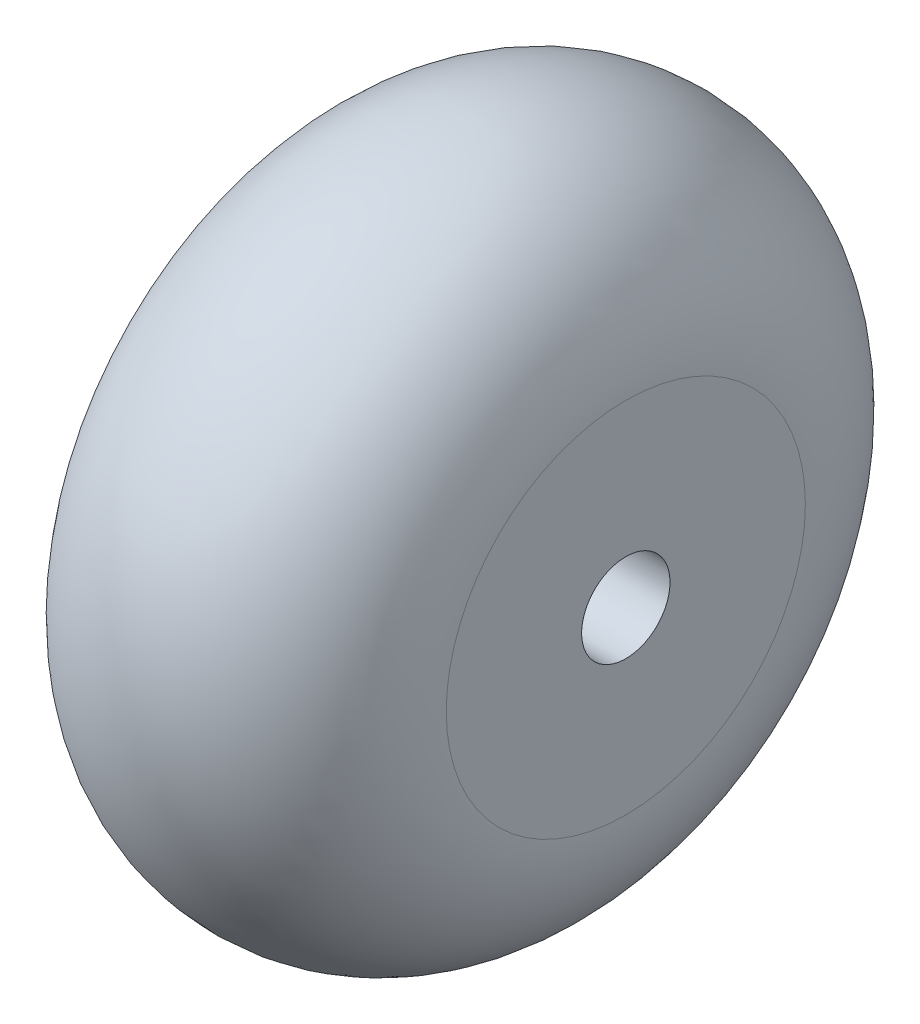
from build123d import *

# Parameters (mm, degrees)
SKETCH_2_R          = 1.6
CUT_EXTRUDE_1_DEPTH = 13


with BuildPart() as part:
    # 草图1 → 旋转2 (revolve)
    with BuildSketch(Plane.XY):
        with BuildLine():
            Line((6, 6.5), (6, 0))
            Line((6, 0), (-6, 0))
            Line((-6, 0), (-6, 6.5))
            ThreePointArc((-6, 6.5), (0, 12.5), (6, 6.5))
        make_face()
    revolve(axis=Axis((-6, 0, 0), (1, 0, 0)))

    # 草图2 → 切除-拉伸1 (cut, through all)
    with BuildSketch(Plane(origin=(6, 0, 0), x_dir=(0, 0, -1), z_dir=(1, 0, 0))):
        Circle(SKETCH_2_R)
    extrude(amount=-CUT_EXTRUDE_1_DEPTH, mode=Mode.SUBTRACT)


solid = part.part
